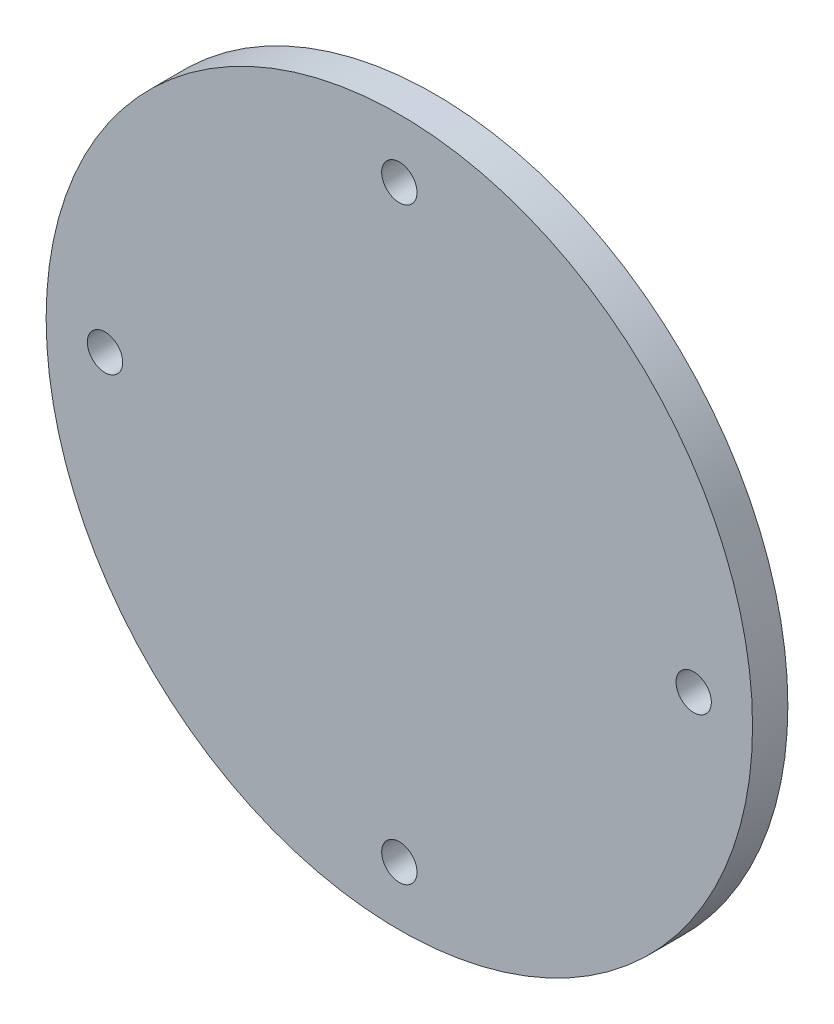
from build123d import *

# Parameters (mm, degrees)
ESQUISSE1_R        = 30
ESQUISSE1_R_2      = 1.5
BOSS_EXTRU_1_DEPTH = 3


with BuildPart() as part:
    # Esquisse1 → Boss.-Extru.1 (new body)
    with BuildSketch(Plane.XY):
        Circle(ESQUISSE1_R)
        with Locations((0, 25)):
            Circle(ESQUISSE1_R_2, mode=Mode.SUBTRACT)
        with Locations((-25, 0)):
            Circle(ESQUISSE1_R_2, mode=Mode.SUBTRACT)
        with Locations((25, 0)):
            Circle(ESQUISSE1_R_2, mode=Mode.SUBTRACT)
        with Locations((0, -25)):
            Circle(ESQUISSE1_R_2, mode=Mode.SUBTRACT)
    extrude(amount=BOSS_EXTRU_1_DEPTH)


solid = part.part
